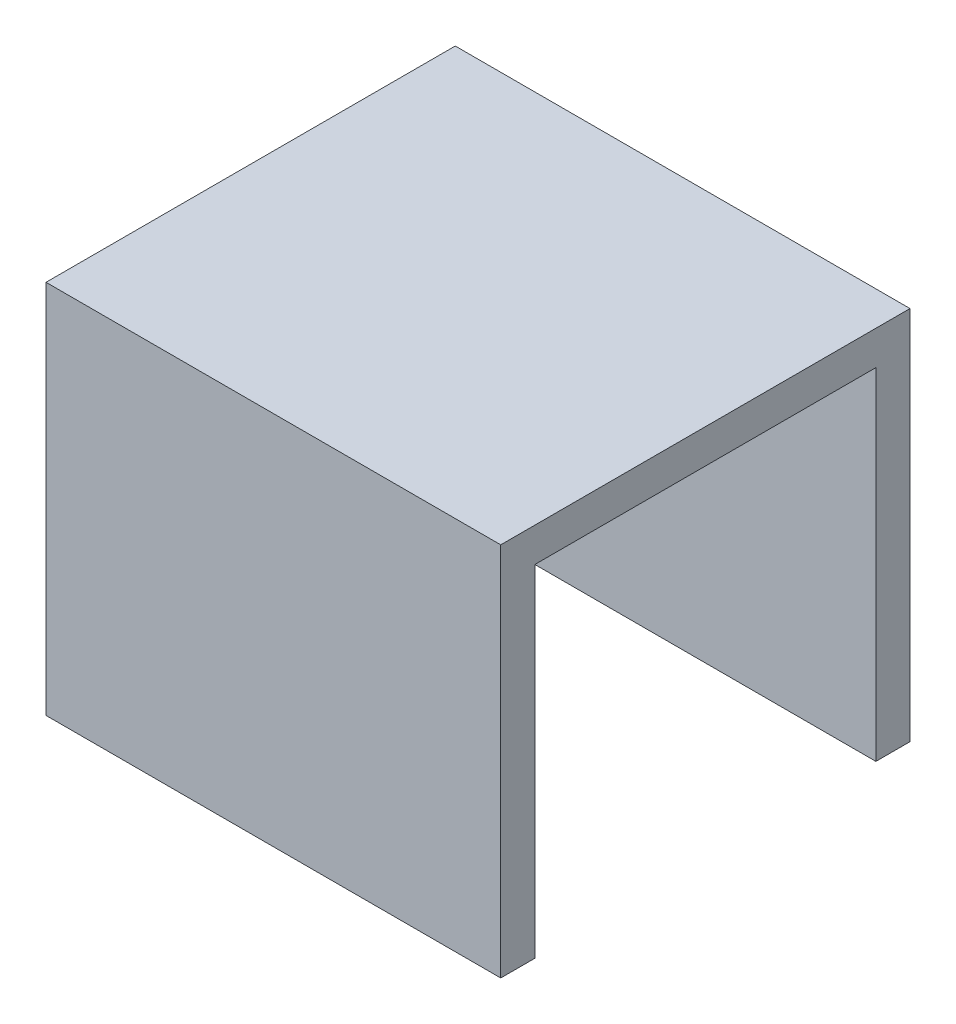
from build123d import *

# Parameters (mm, degrees)
SKETCH1_W           = 20
SKETCH1_H           = 18
BOSS_EXTRUDE1_DEPTH = 16.5
CUT_EXTRUDE1_REACH  = 22
SKETCH2_W           = 15
SKETCH2_H           = 15


with BuildPart() as part:
    # Sketch1 → Boss-Extrude1 (new body)
    with BuildSketch(Plane(origin=(0, 0, 0), x_dir=(1, 0, 0), z_dir=(0, 1, 0))):
        Rectangle(SKETCH1_W, SKETCH1_H)
    extrude(amount=BOSS_EXTRUDE1_DEPTH)

    # Sketch2 → Cut-Extrude1 (cut, up to next)
    with BuildSketch(Plane.ZY.offset(10), mode=Mode.PRIVATE) as cut_extrude1_sk1:
        with Locations((0, 7.5)):
            Rectangle(SKETCH2_W, SKETCH2_H)
    cut_extrude1_tool1 = extrude(cut_extrude1_sk1.sketch, amount=-CUT_EXTRUDE1_REACH, mode=Mode.PRIVATE) & part.part
    add(cut_extrude1_tool1.solids().sort_by_distance((-10, 7.5, 0))[0], mode=Mode.SUBTRACT)


solid = part.part
